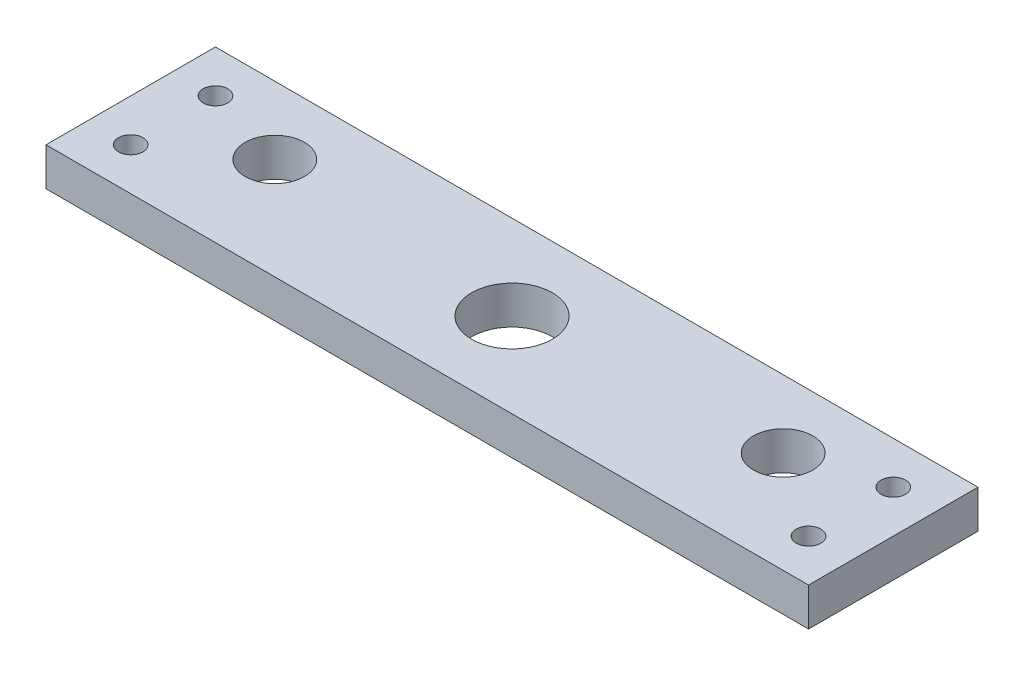
from build123d import *

# Parameters (mm, degrees)
SKETCH1_R           = 1.45
BOSS_EXTRUDE1_DEPTH = 4.5
SKETCH2_R           = 3.5
CUT_EXTRUDE1_DEPTH  = 5.5


with BuildPart() as part:
    # Sketch1 → Boss-Extrude1 (new body)
    with BuildSketch(Plane(origin=(0, 0, 0), x_dir=(1, 0, 0), z_dir=(0, 1, 0))):
        with BuildLine():
            Line((0, 4.7625), (0, 10))
            Line((0, 10), (-45, 10))
            Line((-45, 10), (-45, -10))
            Line((-45, -10), (0, -10))
            Line((0, -10), (0, -4.7625))
            ThreePointArc((0, -4.7625), (-4.7625, 0), (0, 4.7625))
        make_face()
        with Locations((-40, 5)):
            Circle(SKETCH1_R, mode=Mode.SUBTRACT)
        with Locations((-40, -5)):
            Circle(SKETCH1_R, mode=Mode.SUBTRACT)
    boss_extrude1 = extrude(amount=BOSS_EXTRUDE1_DEPTH)

    # Mirror1: Boss-Extrude1 across plane
    add(boss_extrude1.mirror(Plane(origin=(0, 4.5, 10), x_dir=(0, 0, 1), z_dir=(-1, 0, 0))))

    # Sketch2 → Cut-Extrude1 (cut, through all)
    with BuildSketch(Plane(origin=(0, 4.5, 0), x_dir=(1, 0, 0), z_dir=(0, 1, 0))):
        with Locations((-30, 2)):
            Circle(SKETCH2_R)
        with Locations((30, 2)):
            Circle(SKETCH2_R)
    extrude(amount=-CUT_EXTRUDE1_DEPTH, mode=Mode.SUBTRACT)


solid = part.part
